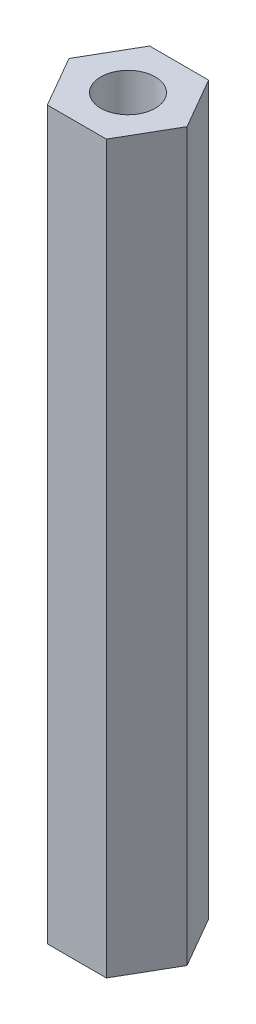
from build123d import *

# Parameters (mm, degrees)
SKETCH_2_R      = 1.5
EXTRUDE_1_DEPTH = 40


with BuildPart() as part:
    # 草图2 → 凸台-拉伸1 (new body)
    with BuildSketch(Plane(origin=(0, 0, 0), x_dir=(1, 0, 0), z_dir=(0, 1, 0))):
        Polygon((-1.625, 2.814582562), (-3.25, 0), (-1.625, -2.814582562), (1.625, -2.814582562), (3.25, 0), (1.625, 2.814582562), align=None)
        Circle(SKETCH_2_R, mode=Mode.SUBTRACT)
    extrude(amount=EXTRUDE_1_DEPTH)


solid = part.part
